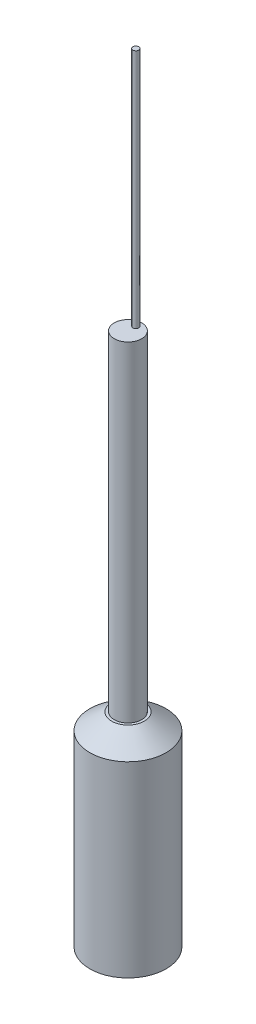
from build123d import *

# Parameters (mm, degrees)
SKETCH1_R           = 5.55
BOSS_EXTRUDE1_DEPTH = 29.62
CHAMFER1_SIZE       = 2.38
CHAMFER1_SIZE2      = 3.175
SKETCH2_R           = 2
BOSS_EXTRUDE2_DEPTH = 48
SKETCH3_R           = 0.43
BOSS_EXTRUDE3_DEPTH = 35


with BuildPart() as part:
    # Sketch1 → Boss-Extrude1 (new body)
    with BuildSketch(Plane(origin=(0, 0, 0), x_dir=(1, 0, 0), z_dir=(0, 1, 0))):
        Circle(SKETCH1_R)
    extrude(amount=BOSS_EXTRUDE1_DEPTH)

    # Chamfer1
    chamfer1_edges = [part.edges().sort_by_distance(p)[0] for p in [
        (-5.55, 29.62, 0),
    ]]
    chamfer1_side = [part.faces().sort_by_distance(p)[0] for p in [
        (-5.55, 14.81, 0),
    ]]
    chamfer(chamfer1_edges, length=CHAMFER1_SIZE, length2=CHAMFER1_SIZE2, reference=chamfer1_side[0])

    # Sketch2 → Boss-Extrude2 (add)
    with BuildSketch(Plane(origin=(0, 29.62, 0), x_dir=(1, 0, 0), z_dir=(0, 1, 0))):
        Circle(SKETCH2_R)
    extrude(amount=BOSS_EXTRUDE2_DEPTH)

    # Sketch3 → Boss-Extrude3 (add)
    with BuildSketch(Plane(origin=(0, 77.62, 0), x_dir=(1, 0, 0), z_dir=(0, 1, 0))):
        with Locations((0, 1.143312096)):
            Circle(SKETCH3_R)
    extrude(amount=BOSS_EXTRUDE3_DEPTH)


solid = part.part
